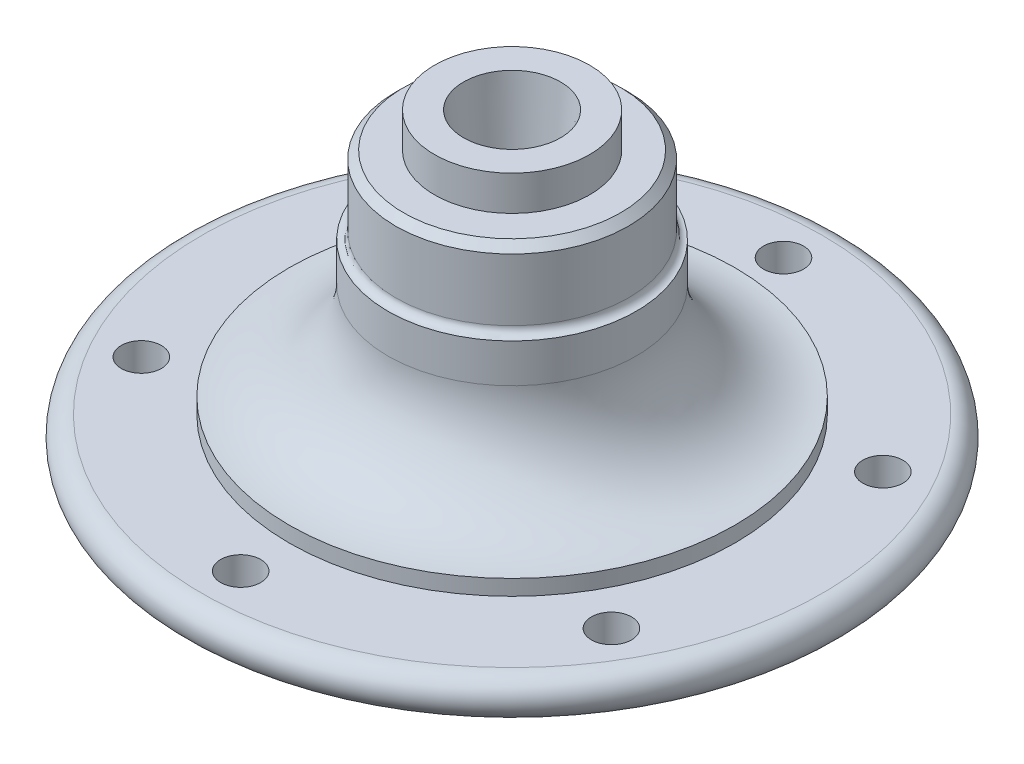
from build123d import *

# Parameters (mm, degrees)
CROQUIS2_R            = 12.5
CORTAR_EXTRUIR1_DEPTH = 20
CORTAR_EXTRUIR1_TAPER = 5
CROQUIS3_R            = 5.164873121
CORTAR_EXTRUIR2_DEPTH = 79.0000001
MATRIZC2_COUNT        = 6


with BuildPart() as part:
    # Croquis1 → Revolución1 (revolve)
    with BuildSketch(Plane.XY):
        with BuildLine():
            Line((0, 0), (0, 90))
            Line((0, 90), (20, 90))
            Line((20, 90), (20, 81))
            Line((20, 81), (28, 81))
            Line((28, 81), (30, 79))
            Line((30, 79), (30, 62.9949995))
            ThreePointArc((30, 62.9949995), (30.585786438, 61.580785938), (32, 60.9949995))
            Line((32, 60.9949995), (32, 50.9949995))
            ThreePointArc((32, 50.9949995), (39.5, 33.141428429), (57.5, 26))
            Line((57.5, 26), (57.5, 22))
            Line((57.5, 22), (80, 22))
            ThreePointArc((80, 22), (85, 17), (80, 12))
            Line((80, 12), (40, 12))
            Line((40, 12), (40, 0))
            Line((40, 0), (0, 0))
        make_face()
    revolve(axis=Axis((0, 0, 0), (0, 1, 0)))

    # Croquis2 → Cortar-Extruir1 (cut)
    with BuildSketch(Plane(origin=(0, 90, 0), x_dir=(1, 0, 0), z_dir=(0, 1, 0))):
        Circle(CROQUIS2_R)
    extrude(amount=-CORTAR_EXTRUIR1_DEPTH, taper=CORTAR_EXTRUIR1_TAPER, mode=Mode.SUBTRACT)

    # Croquis3 → Cortar-Extruir2 (cut, through all)
    with BuildSketch(Plane.XZ.offset(-12)):
        with Locations((0, 70)):
            Circle(CROQUIS3_R)
    cortar_extruir2 = extrude(amount=-CORTAR_EXTRUIR2_DEPTH, mode=Mode.SUBTRACT)

    # MatrizC2: Cortar-Extruir2 ×6 about axis
    matrizc2_axis = Axis((0, 0, 0), (0, 1, 0))
    for i in range(1, MATRIZC2_COUNT):
        add(cortar_extruir2.rotate(matrizc2_axis, i * 360 / MATRIZC2_COUNT), mode=Mode.SUBTRACT)


solid = part.part
